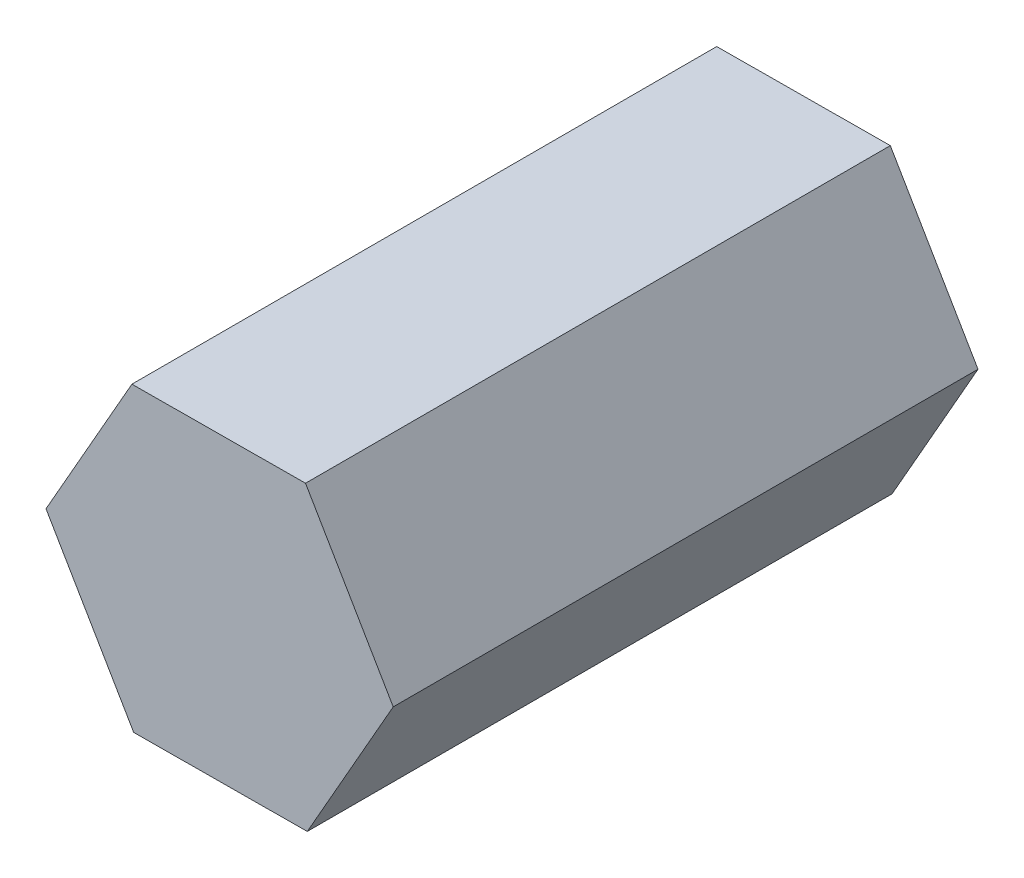
from build123d import *

# Parameters (mm, degrees)
ESTRUSIONE_ESTRUSIONE1_DEPTH = 160


with BuildPart() as part:
    # Schizzo1 → Estrusione-Estrusione1 (new body)
    with BuildSketch(Plane.XY):
        Polygon((-23.990495347, 40.996416099), (-47.49918548, -0.27817037), (-23.508690133, -41.27458647), (23.990495347, -40.996416099), (47.49918548, 0.27817037), (23.508690133, 41.27458647), align=None)
    extrude(amount=ESTRUSIONE_ESTRUSIONE1_DEPTH)


solid = part.part
